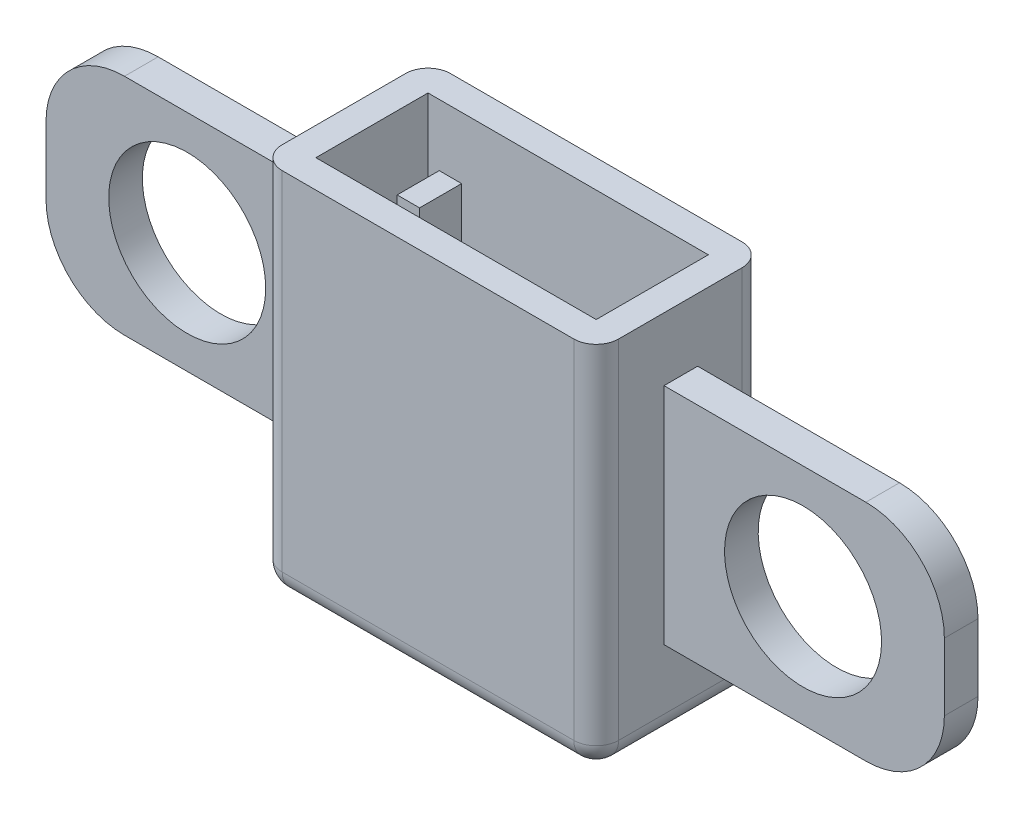
from build123d import *

# Parameters (mm, degrees)
SKETCH1_W           = 30
SKETCH1_H           = 15
BOSS_EXTRUDE1_DEPTH = 33
SKETCH2_W           = 25
SKETCH2_H           = 10
CUT_EXTRUDE1_DEPTH  = 30.5
SKETCH3_W           = 23
SKETCH3_H           = 2.5
CUT_EXTRUDE2_DEPTH  = 30.5
SKETCH4_W           = 2
SKETCH4_H           = 3.75
BOSS_EXTRUDE2_DEPTH = 25
SKETCH5_W           = 2
SKETCH5_H           = 3.75
BOSS_EXTRUDE3_DEPTH = 25
SKETCH6_W           = 2
SKETCH6_H           = 3.75
BOSS_EXTRUDE4_DEPTH = 25
SKETCH7_W           = 2
SKETCH7_H           = 3.75
BOSS_EXTRUDE5_DEPTH = 25
FILLET1_R           = 2
BOSS_EXTRUDE6_DEPTH = 25
CUT_EXTRUDE3_DEPTH  = 25
FILLET2_R           = 7
FILLET3_R           = 7
BOSS_EXTRUDE7_DEPTH = 25
CUT_EXTRUDE4_DEPTH  = 25
FILLET4_R           = 7


with BuildPart() as part:
    # Sketch1 → Boss-Extrude1 (new body)
    with BuildSketch(Plane(origin=(0, 0, 0), x_dir=(1, 0, 0), z_dir=(0, 1, 0))):
        Rectangle(SKETCH1_W, SKETCH1_H)
    extrude(amount=BOSS_EXTRUDE1_DEPTH)

    # Sketch2 → Cut-Extrude1 (cut)
    with BuildSketch(Plane(origin=(0, 33, 0), x_dir=(1, 0, 0), z_dir=(0, 1, 0))):
        Rectangle(SKETCH2_W, SKETCH2_H)
    extrude(amount=-CUT_EXTRUDE1_DEPTH, mode=Mode.SUBTRACT)

    # Sketch3 → Cut-Extrude2 (cut)
    with BuildSketch(Plane(origin=(0, 2.5, 0), x_dir=(1, 0, 0), z_dir=(0, 1, 0))):
        Rectangle(SKETCH3_W, SKETCH3_H)
    extrude(amount=-CUT_EXTRUDE2_DEPTH, mode=Mode.SUBTRACT)

    # Sketch4 → Boss-Extrude2 (add)
    with BuildSketch(Plane(origin=(0, 2.5, 0), x_dir=(1, 0, 0), z_dir=(0, 1, 0))):
        with Locations((-10.5, -3.125)):
            Rectangle(SKETCH4_W, SKETCH4_H)
    extrude(amount=BOSS_EXTRUDE2_DEPTH)

    # Sketch5 → Boss-Extrude3 (add)
    with BuildSketch(Plane(origin=(0, 2.5, 0), x_dir=(1, 0, 0), z_dir=(0, 1, 0))):
        with Locations((10.5, -3.125)):
            Rectangle(SKETCH5_W, SKETCH5_H)
    extrude(amount=BOSS_EXTRUDE3_DEPTH)

    # Sketch6 → Boss-Extrude4 (add)
    with BuildSketch(Plane(origin=(0, 2.5, 0), x_dir=(1, 0, 0), z_dir=(0, 1, 0))):
        with Locations((-10.5, 3.125)):
            Rectangle(SKETCH6_W, SKETCH6_H)
    extrude(amount=BOSS_EXTRUDE4_DEPTH)

    # Sketch7 → Boss-Extrude5 (add)
    with BuildSketch(Plane(origin=(0, 2.5, 0), x_dir=(1, 0, 0), z_dir=(0, 1, 0))):
        with Locations((10.5, 3.125)):
            Rectangle(SKETCH7_W, SKETCH7_H)
    extrude(amount=BOSS_EXTRUDE5_DEPTH)

    # Fillet1
    fillet1_edges = [part.edges().sort_by_distance(p)[0] for p in [
        (0, 0, 7.5),
        (-15, 0, 0),
        (0, 0, -7.5),
        (15, 0, 0),
        (15, 16.5, 7.5),
        (-15, 16.5, 7.5),
        (-15, 16.5, -7.5),
        (15, 16.5, -7.5),
    ]]
    fillet(fillet1_edges, radius=FILLET1_R)

    # Sketch8 → Boss-Extrude6 (add)
    with BuildSketch(Plane.ZY.offset(15)):
        Polygon((1.563932113, 13.092554953), (-1.436067887, 21.547100408), (-1.436067887, 7.31982768), (1.563932113, 7.31982768), align=None)
        Polygon((-1.436067887, 27.31982768), (-1.436067887, 21.547100408), (1.563932113, 13.092554953), (1.563932113, 27.31982768), align=None)
    extrude(amount=BOSS_EXTRUDE6_DEPTH)

    # Sketch9 → Cut-Extrude3 (cut)
    with BuildSketch(Plane.XY.offset(1.563932113)):
        with BuildLine():
            ThreePointArc((-20.409219381, 17.247203185), (-25.092170791, 23.852601419), (-32.875301047, 21.620068518))
            Line((-32.875301047, 21.620068518), (-21.943137715, 12.874337852))
            ThreePointArc((-21.943137715, 12.874337852), (-20.803821147, 14.930154595), (-20.409219381, 17.247203185))
        make_face()
        with BuildLine():
            Line((-21.943137715, 12.874337852), (-32.875301047, 21.620068518))
            ThreePointArc((-32.875301047, 21.620068518), (-31.782084714, 11.781121519), (-21.943137715, 12.874337852))
        make_face()
    extrude(amount=-CUT_EXTRUDE3_DEPTH, mode=Mode.SUBTRACT)

    # Fillet2
    fillet2_edges = [part.edges().sort_by_distance(p)[0] for p in [
        (-40, 7.31982768, 0.063932113),
    ]]
    fillet(fillet2_edges, radius=FILLET2_R)

    # Fillet3
    fillet3_edges = [part.edges().sort_by_distance(p)[0] for p in [
        (-40, 27.31982768, 0.063932113),
    ]]
    fillet(fillet3_edges, radius=FILLET3_R)

    # Sketch10 → Boss-Extrude7 (add)
    with BuildSketch(Plane(origin=(15, 0, 0), x_dir=(0, 0, -1), z_dir=(1, 0, 0))):
        Polygon((1.545363578, 13.144884462), (-1.454636422, 21.599429916), (-1.454636422, 7.372157189), (1.545363578, 7.372157189), align=None)
        Polygon((-1.454636422, 27.372157189), (-1.454636422, 21.599429916), (1.545363578, 13.144884462), (1.545363578, 27.372157189), align=None)
    extrude(amount=BOSS_EXTRUDE7_DEPTH)

    # Sketch11 → Cut-Extrude4 (cut)
    with BuildSketch(Plane(origin=(0, 0, -1.545363578), x_dir=(-1, 0, 0), z_dir=(0, 0, -1))):
        with BuildLine():
            ThreePointArc((-20.397153498, 17.289879987), (-25.080104908, 23.895278222), (-32.863235164, 21.66274532))
            Line((-32.863235164, 21.66274532), (-21.931071832, 12.917014654))
            ThreePointArc((-21.931071832, 12.917014654), (-20.791755264, 14.972831397), (-20.397153498, 17.289879987))
        make_face()
        with BuildLine():
            Line((-21.931071832, 12.917014654), (-32.863235164, 21.66274532))
            ThreePointArc((-32.863235164, 21.66274532), (-31.770018831, 11.823798321), (-21.931071832, 12.917014654))
        make_face()
    extrude(amount=-CUT_EXTRUDE4_DEPTH, mode=Mode.SUBTRACT)

    # Fillet4
    fillet4_edges = [part.edges().sort_by_distance(p)[0] for p in [
        (40, 27.372157189, -0.045363578),
        (40, 7.372157189, -0.045363578),
    ]]
    fillet(fillet4_edges, radius=FILLET4_R)


solid = part.part
